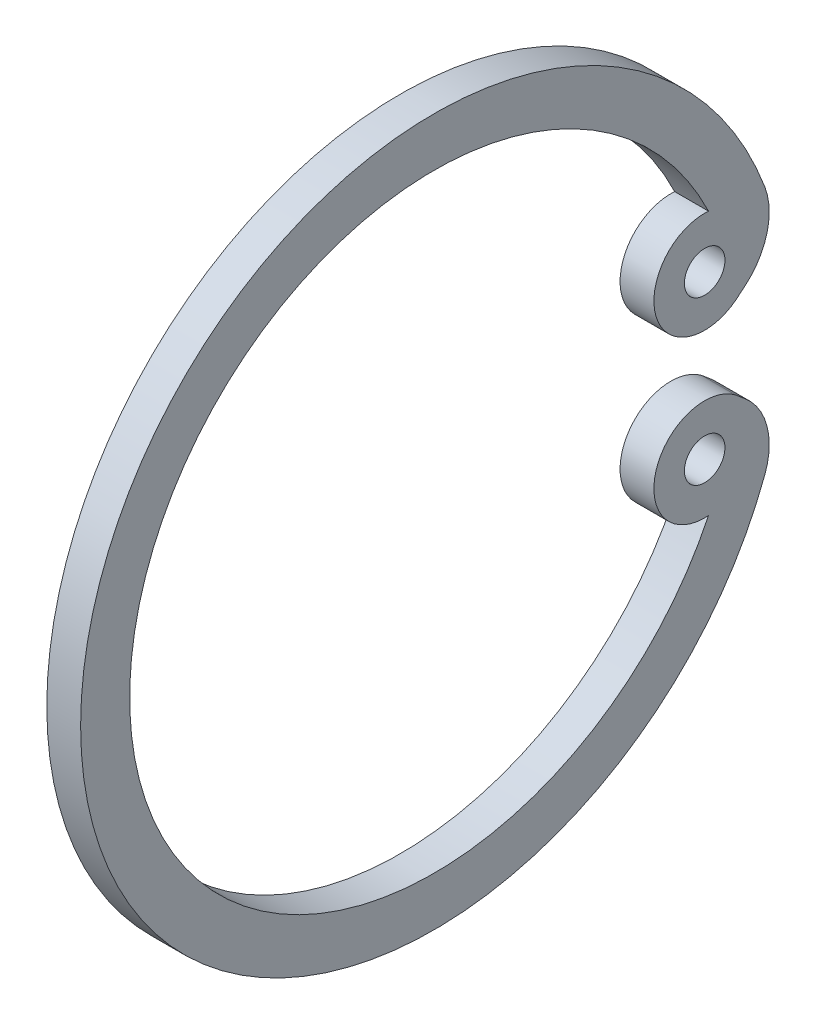
from build123d import *

# Parameters (mm, degrees)
SKETCH1_R           = 0.6
BOSS_EXTRUDE1_DEPTH = 1
SCALE1_SCALE        = 0.222222222
SCALE2_SCALE        = 1.25


with BuildPart() as part:
    # Sketch1 → Boss-Extrude1 (new body)
    with BuildSketch(Plane(origin=(19, 0, 0), x_dir=(0, 0, -1), z_dir=(1, 0, 0))):
        with BuildLine():
            Line((-1.082906578, 1.214226965), (-0.806260325, 1.444819657))
            ThreePointArc((-0.806260325, 1.444819657), (-0.157167996, 2.46989624), (-0.220083072, 3.681566388))
            ThreePointArc((-0.220083072, 3.681566388), (-20.449170804, -0.000103807), (-0.220095755, -3.681843689))
            ThreePointArc((-0.220095755, -3.681843689), (-0.157177378, -2.470170425), (-0.806270581, -1.44509051))
            Line((-0.806270581, -1.44509051), (-1.082193901, -1.213563353))
            ThreePointArc((-1.082193901, -1.213563353), (-3.437745717, -1.969386585), (-1.886859109, -3.896727719))
            ThreePointArc((-1.886859109, -3.896727719), (-18.999593972, -0.000121806), (-1.886859109, 3.896484108))
            ThreePointArc((-1.886859109, 3.896484108), (-3.437385157, 1.97013231), (-1.082906578, 1.214226965))
        make_face()
        with Locations((-2.00000003, -2.4)):
            Circle(SKETCH1_R, mode=Mode.SUBTRACT)
        with Locations((-2.00000003, 2.4)):
            Circle(SKETCH1_R, mode=Mode.SUBTRACT)
    extrude(amount=-BOSS_EXTRUDE1_DEPTH)


with BuildPart() as part_1:
    # Scale1: scaled about (18.5, -0.000178585, 9.916688181)
    add(part.part.scale(SCALE1_SCALE).moved(Location((14.388888889, -0.000138899, 7.712979696))))


with BuildPart() as part_2:
    # Scale2: scaled about (18.5, -0.000178585, 9.916688181)
    add(part_1.part.scale(SCALE2_SCALE).moved(Location((-4.625, 4.4646e-05, -2.479172045))))


solid = part_2.part
